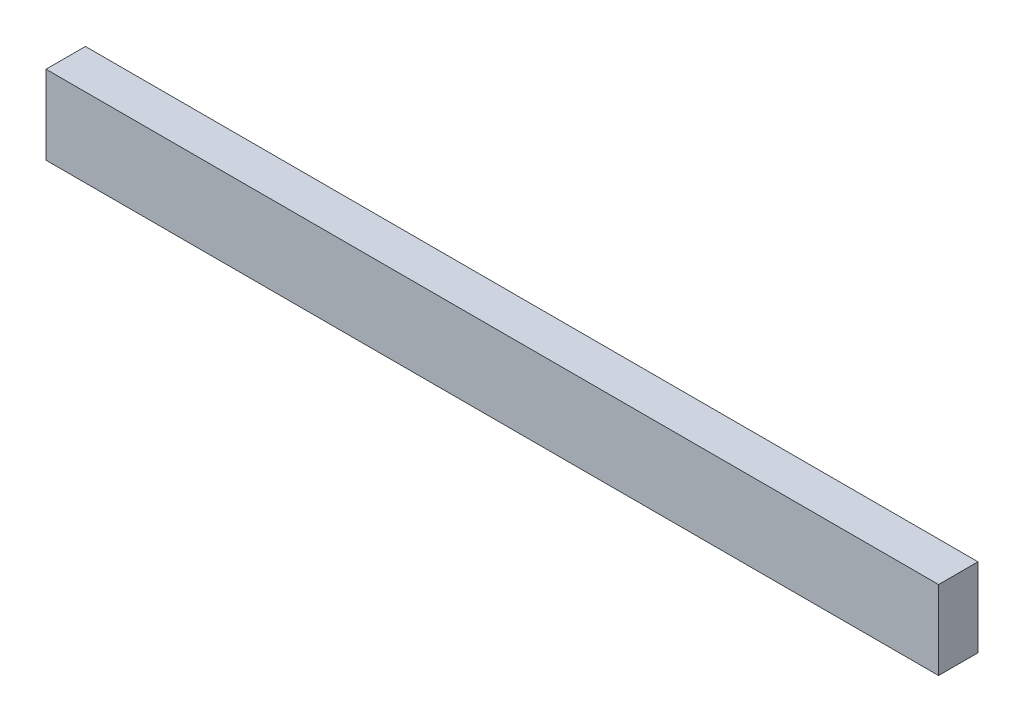
from build123d import *

# Parameters (mm, degrees)
SKETCH1_W           = 431.3428
SKETCH1_H           = 38.1
BOSS_EXTRUDE1_DEPTH = 19.05


with BuildPart() as part:
    # Sketch1 → Boss-Extrude1 (new body)
    with BuildSketch(Plane.XY):
        with Locations((41.431611053, 11.671767895)):
            Rectangle(SKETCH1_W, SKETCH1_H)
    extrude(amount=BOSS_EXTRUDE1_DEPTH)


solid = part.part
